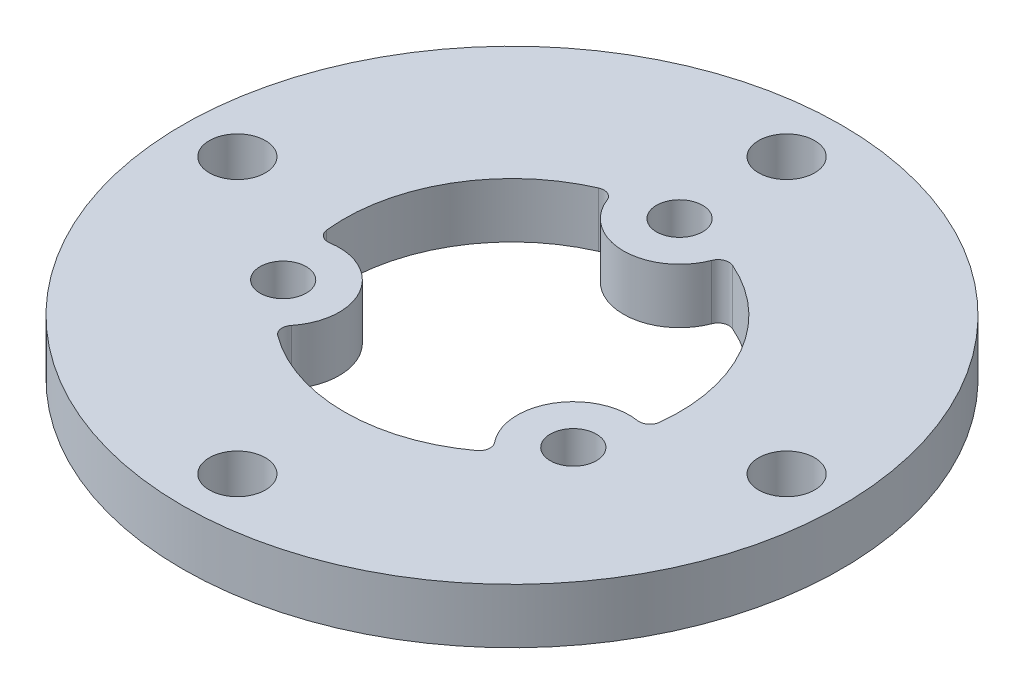
from build123d import *

# Parameters (mm, degrees)
SKETCH1_R           = 30
SKETCH1_R_2         = 10
SKETCH1_R_3         = 2.1
SKETCH1_R_4         = 2.55
BOSS_EXTRUDE1_DEPTH = 5
CUT_EXTRUDE1_DEPTH  = 6
FILLET1_R           = 1


with BuildPart() as part:
    # Sketch1 → Boss-Extrude1 (new body)
    with BuildSketch(Plane(origin=(0, 0, 0), x_dir=(1, 0, 0), z_dir=(0, 1, 0))):
        Circle(SKETCH1_R)
        Circle(SKETCH1_R_2, mode=Mode.SUBTRACT)
        with Locations((0, 15.25)):
            Circle(SKETCH1_R_3, mode=Mode.SUBTRACT)
        with Locations((13.206887408, -7.625)):
            Circle(SKETCH1_R_3, mode=Mode.SUBTRACT)
        with Locations((-13.206887408, -7.625)):
            Circle(SKETCH1_R_3, mode=Mode.SUBTRACT)
        with Locations((0, 25)):
            Circle(SKETCH1_R_4, mode=Mode.SUBTRACT)
        with Locations((25, 0)):
            Circle(SKETCH1_R_4, mode=Mode.SUBTRACT)
        with Locations((0, -25)):
            Circle(SKETCH1_R_4, mode=Mode.SUBTRACT)
        with Locations((-25, 0)):
            Circle(SKETCH1_R_4, mode=Mode.SUBTRACT)
    extrude(amount=BOSS_EXTRUDE1_DEPTH)

    # Sketch2 → Cut-Extrude1 (cut, through all)
    with BuildSketch(Plane(origin=(0, 5, 0), x_dir=(1, 0, 0), z_dir=(0, 1, 0))):
        with BuildLine():
            ThreePointArc((-5.028195952, 14.397213115), (0, 10.15), (5.028195952, 14.397213115))
            ThreePointArc((5.028195952, 14.397213115), (13.206887408, 7.625), (14.982450277, -2.844061128))
            ThreePointArc((14.982450277, -2.844061128), (8.790157848, -5.075), (9.954254325, -11.553151987))
            ThreePointArc((9.954254325, -11.553151987), (0, -15.25), (-9.954254325, -11.553151987))
            ThreePointArc((-9.954254325, -11.553151987), (-8.790157848, -5.075), (-14.982450277, -2.844061128))
            ThreePointArc((-14.982450277, -2.844061128), (-13.206887408, 7.625), (-5.028195952, 14.397213115))
        make_face()
    extrude(amount=-CUT_EXTRUDE1_DEPTH, mode=Mode.SUBTRACT)

    # Fillet1
    fillet1_edges = [part.edges().sort_by_distance(p)[0] for p in [
        (-14.982450277, 2.5, 2.844061128),
        (-5.028195952, 2.5, -14.397213115),
        (5.028195952, 2.5, -14.397213115),
        (14.982450277, 2.5, 2.844061128),
        (9.954254325, 2.5, 11.553151987),
        (-9.954254325, 2.5, 11.553151987),
    ]]
    fillet(fillet1_edges, radius=FILLET1_R)


solid = part.part
